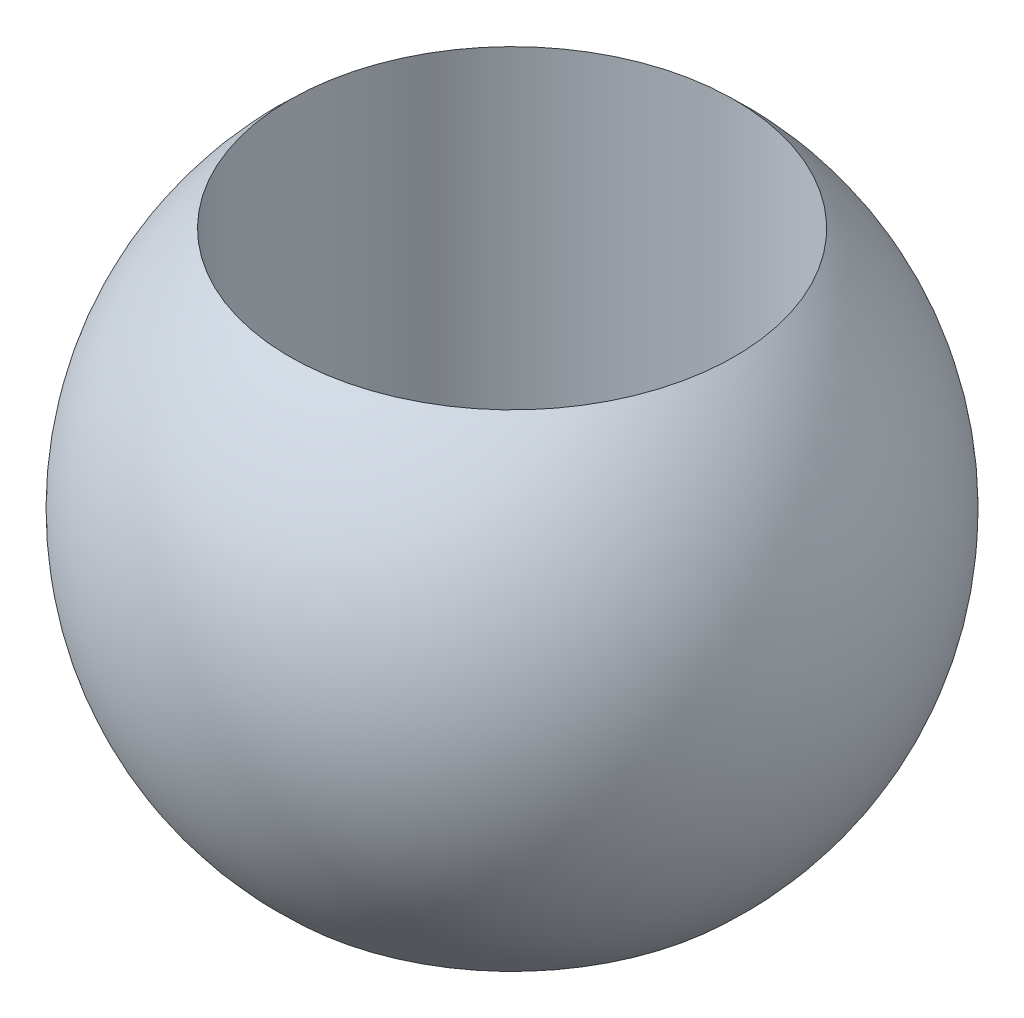
from build123d import *


with BuildPart() as part:
    # Sketch1 → Revolve1 (revolve)
    with BuildSketch(Plane.XY):
        with BuildLine():
            ThreePointArc((1.3716, -1.499245624), (2.032, 0), (1.3716, 1.499245624))
            Line((1.3716, 1.499245624), (1.3716, -1.499245624))
        make_face()
    revolve(axis=Axis((0, 2.032, 0), (0, -1, 0)))


solid = part.part
